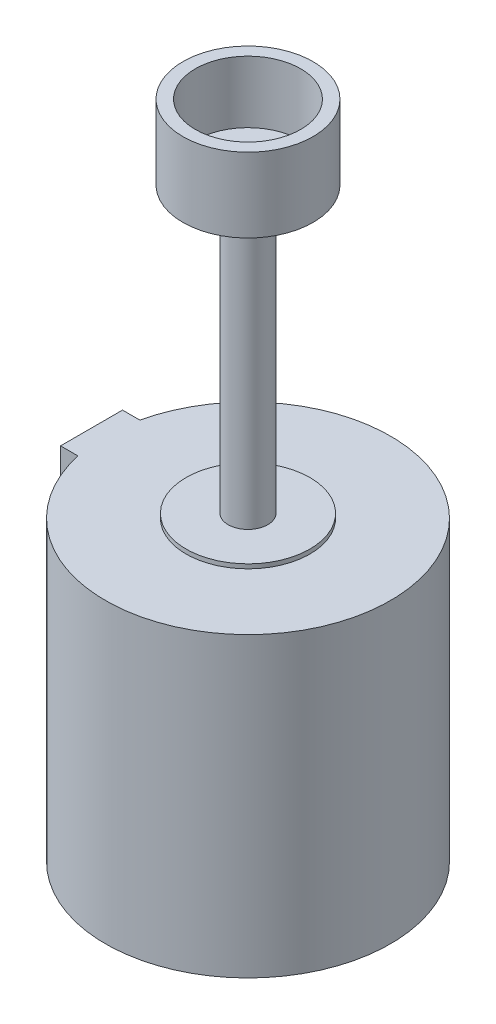
from build123d import *

# Parameters (mm, degrees)
SKETCH1_R           = 16
BOSS_EXTRUDE1_DEPTH = 229.5
SKETCH2_R           = 52.5
BOSS_EXTRUDE2_DEPTH = 60
SKETCH3_R           = 42.5
CUT_EXTRUDE1_DEPTH  = 50
SKETCH6_R           = 50
BOSS_EXTRUDE4_DEPTH = 3.5
BOSS_EXTRUDE5_DEPTH = 240
SKETCH8_R           = 110
CUT_EXTRUDE3_DEPTH  = 50


with BuildPart() as part:
    # Sketch1 → Boss-Extrude1 (new body)
    with BuildSketch(Plane(origin=(0, 0, 0), x_dir=(1, 0, 0), z_dir=(0, 1, 0))):
        Circle(SKETCH1_R)
    extrude(amount=BOSS_EXTRUDE1_DEPTH)

    # Sketch2 → Boss-Extrude2 (add)
    with BuildSketch(Plane(origin=(0, 229.5, 0), x_dir=(1, 0, 0), z_dir=(0, 1, 0))):
        Circle(SKETCH2_R)
    extrude(amount=BOSS_EXTRUDE2_DEPTH)

    # Sketch3 → Cut-Extrude1 (cut)
    with BuildSketch(Plane(origin=(0, 289.5, 0), x_dir=(1, 0, 0), z_dir=(0, 1, 0))):
        Circle(SKETCH3_R)
    extrude(amount=-CUT_EXTRUDE1_DEPTH, mode=Mode.SUBTRACT)

    # Sketch6 → Boss-Extrude4 (add)
    with BuildSketch(Plane.XZ):
        Circle(SKETCH6_R)
    extrude(amount=BOSS_EXTRUDE4_DEPTH)

    # Sketch7 → Boss-Extrude5 (add)
    with BuildSketch(Plane.XZ.offset(3.5)):
        with BuildLine():
            Line((-126.279721603, -25), (-112.249721603, -25))
            ThreePointArc((-112.249721603, -25), (115, 0), (-112.249721603, 25))
            Line((-112.249721603, 25), (-126.279721603, 25))
            Line((-126.279721603, 25), (-126.279721603, -25))
        make_face()
    extrude(amount=BOSS_EXTRUDE5_DEPTH)

    # Sketch8 → Cut-Extrude3 (cut)
    with BuildSketch(Plane.XZ.offset(243.5)):
        Circle(SKETCH8_R)
    extrude(amount=-CUT_EXTRUDE3_DEPTH, mode=Mode.SUBTRACT)


solid = part.part
